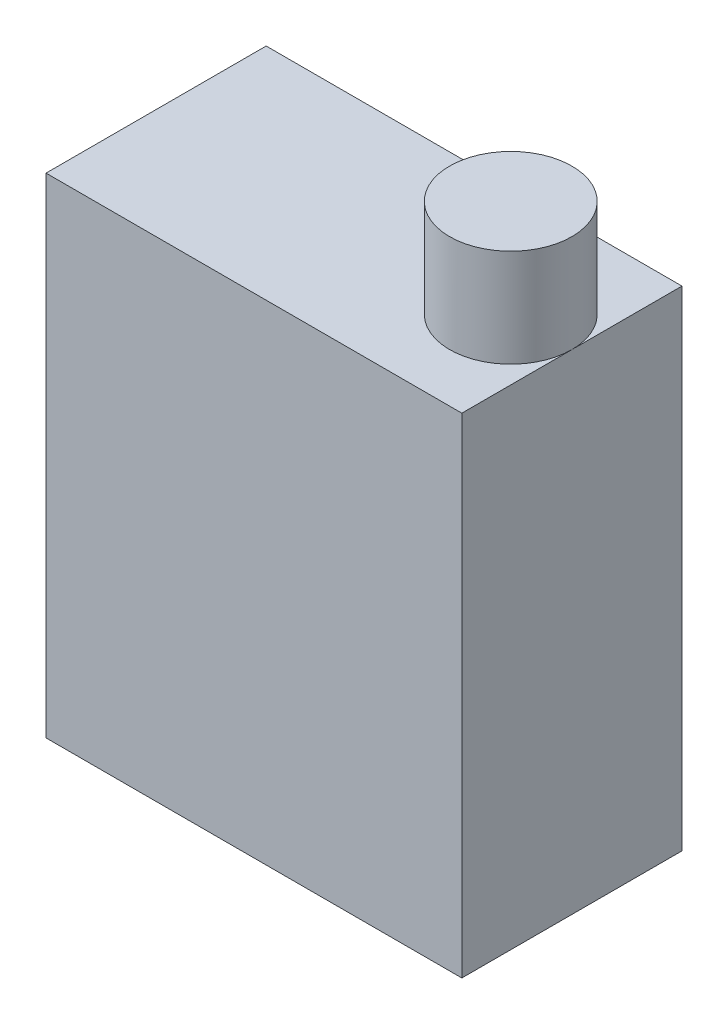
from build123d import *

# Parameters (mm, degrees)
SKETCH1_W           = 4.318
SKETCH1_H           = 2.286
BOSS_EXTRUDE1_DEPTH = 5.08
SKETCH2_R           = 0.635
BOSS_EXTRUDE2_DEPTH = 1.016


with BuildPart() as part:
    # Sketch1 → Boss-Extrude1 (new body)
    with BuildSketch(Plane(origin=(0, 0, 0), x_dir=(1, 0, 0), z_dir=(0, 1, 0))):
        with Locations((-2.8194, -0.2794)):
            Rectangle(SKETCH1_W, SKETCH1_H)
    extrude(amount=BOSS_EXTRUDE1_DEPTH)

    # Sketch2 → Boss-Extrude2 (add)
    with BuildSketch(Plane(origin=(0, 5.08, 0), x_dir=(1, 0, 0), z_dir=(0, 1, 0))):
        with Locations((-1.2954, -0.2794)):
            Circle(SKETCH2_R)
    extrude(amount=BOSS_EXTRUDE2_DEPTH)


solid = part.part
